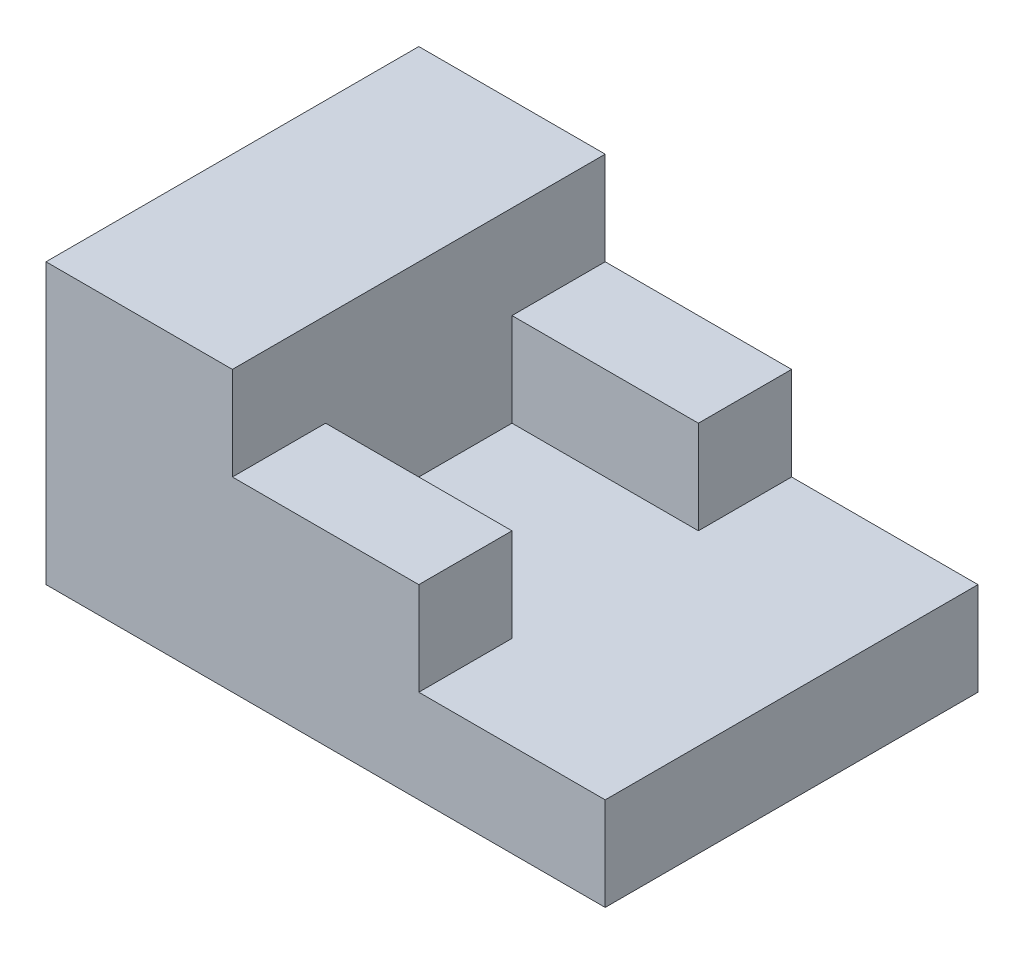
from build123d import *

# Parameters (mm, degrees)
SKETCH_1_W      = 30
SKETCH_1_H      = 20
EXTRUDE_1_DEPTH = 5
EXTRUDE_2_DEPTH = 10
EXTRUDE_3_DEPTH = 15
SCALE_1_SCALE   = 0.2


with BuildPart() as part:
    # 草圖1 → 填料-伸長1 (new body)
    with BuildSketch(Plane(origin=(0, 0, 0), x_dir=(1, 0, 0), z_dir=(0, 1, 0))):
        Rectangle(SKETCH_1_W, SKETCH_1_H)
    extrude(amount=EXTRUDE_1_DEPTH)

    # 草圖1<3> → 填料-伸長2 (add)
    with BuildSketch(Plane(origin=(0, 0, 0), x_dir=(1, 0, 0), z_dir=(0, 1, 0))):
        Polygon((5, 10), (-15, 10), (-15, -10), (5, -10), (5, -5), (-5, -5), (-5, 5), (5, 5), align=None)
    extrude(amount=EXTRUDE_2_DEPTH)

    # 草圖1<4> → 填料-伸長3 (add)
    with BuildSketch(Plane(origin=(0, 0, 0), x_dir=(1, 0, 0), z_dir=(0, 1, 0))):
        Polygon((-5, 5), (-5, 10), (-15, 10), (-15, -10), (-5, -10), (-5, -5), align=None)
    extrude(amount=EXTRUDE_3_DEPTH)


with BuildPart() as part_1:
    # 縮放比例1: scaled about (-3.636363636, 5.681818182, 0)
    add(part.part.scale(SCALE_1_SCALE).moved(Location((-2.909090909, 4.545454546, 0))))


solid = part_1.part
